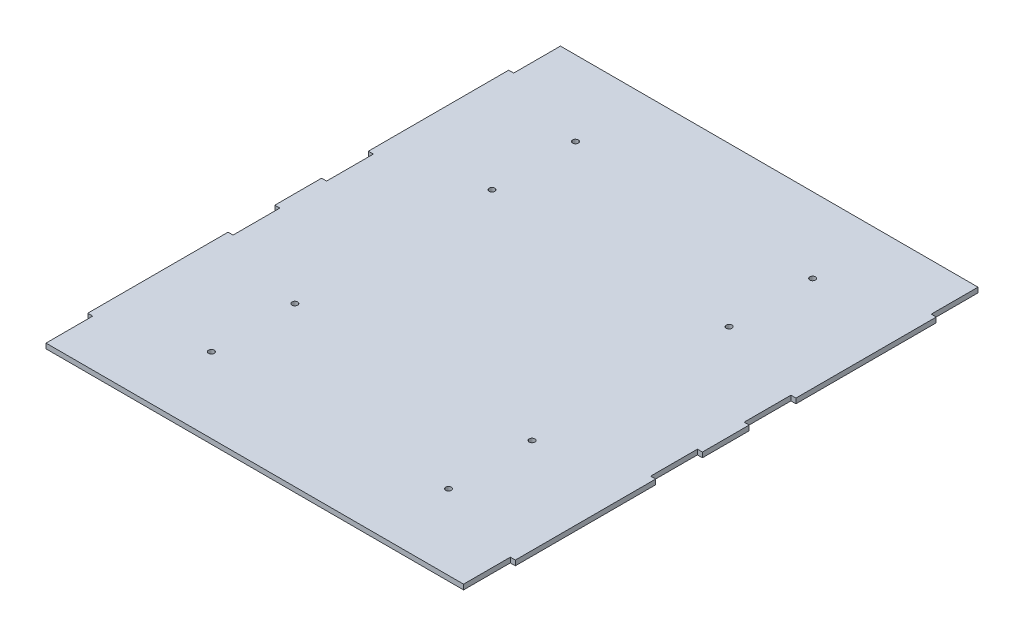
from build123d import *

# Parameters (mm, degrees)
CROQUIS1_R              = 1.7
SALIENTE_EXTRUIR1_DEPTH = 3


with BuildPart() as part:
    # Croquis1 → Saliente-Extruir1 (new body)
    with BuildSketch(Plane(origin=(0, 0, 0), x_dir=(1, 0, 0), z_dir=(0, 1, 0))):
        Polygon((-97.174990899, 154.00569786), (152.825009101, 154.00569786), (152.825009101, 126.00569786), (155.825009101, 126.00569786), (155.825009101, 42.00569786), (152.825009101, 42.00569786), (152.825009101, 14.00569786), (155.825009101, 14.00569786), (155.825009101, -13.99430214), (152.825009101, -13.99430214), (152.825009101, -41.99430214), (155.825009101, -41.99430214), (155.825009101, -125.99430214), (152.825009101, -125.99430214), (152.825009101, -153.99430214), (-97.174990899, -153.99430214), (-97.174990899, -125.99430214), (-100.174990899, -125.99430214), (-100.174990899, -41.99430214), (-97.174990899, -41.99430214), (-97.174990899, -13.99430214), (-100.174990899, -13.99430214), (-100.174990899, 14.00569786), (-97.174990899, 14.00569786), (-97.174990899, 42.00569786), (-100.174990899, 42.00569786), (-100.174990899, 126.00569786), (-97.174990899, 126.00569786), align=None)
        with Locations((-43.174990899, 109.01139572)):
            Circle(CROQUIS1_R, mode=Mode.SUBTRACT)
        with Locations((-43.174990899, 59)):
            Circle(CROQUIS1_R, mode=Mode.SUBTRACT)
        with Locations((-43.174990899, -58.99430214)):
            Circle(CROQUIS1_R, mode=Mode.SUBTRACT)
        with Locations((-43.174990899, -108.99430214)):
            Circle(CROQUIS1_R, mode=Mode.SUBTRACT)
        with Locations((98.825009101, 59)):
            Circle(CROQUIS1_R, mode=Mode.SUBTRACT)
        with Locations((98.825009101, 109.01139572)):
            Circle(CROQUIS1_R, mode=Mode.SUBTRACT)
        with Locations((98.825009101, -108.99430214)):
            Circle(CROQUIS1_R, mode=Mode.SUBTRACT)
        with Locations((98.825009101, -58.99430214)):
            Circle(CROQUIS1_R, mode=Mode.SUBTRACT)
    extrude(amount=SALIENTE_EXTRUIR1_DEPTH)


solid = part.part
